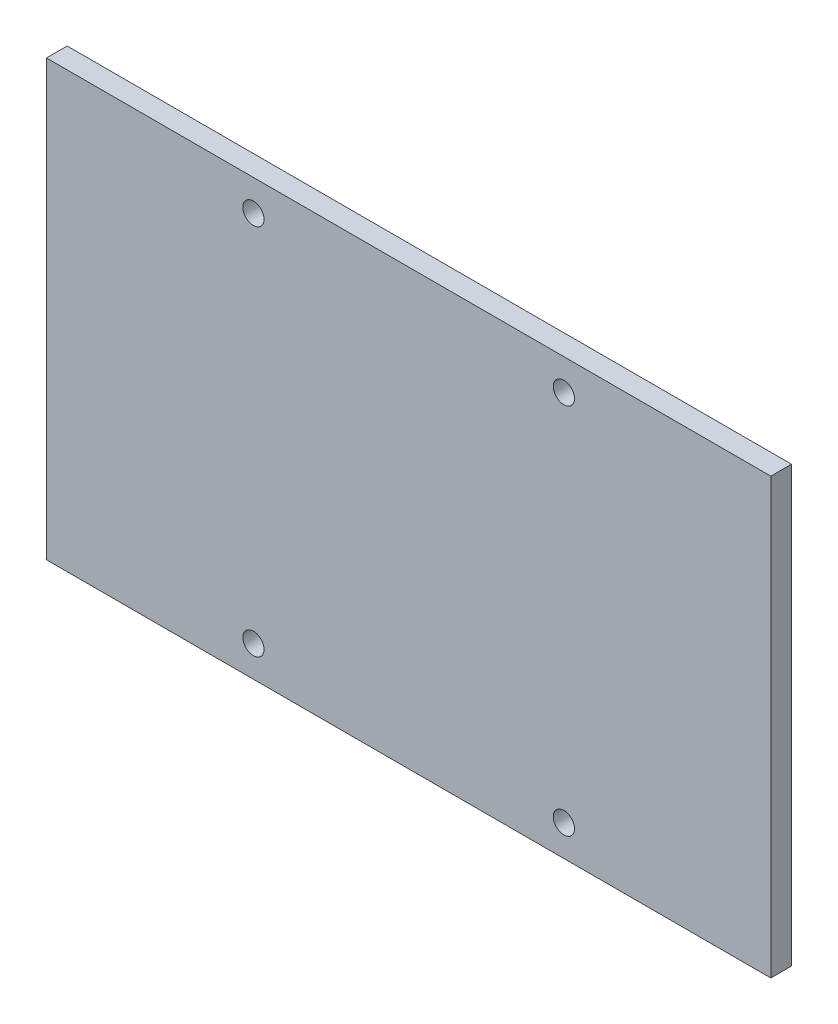
from build123d import *

# Parameters (mm, degrees)
SKETCH_1_W      = 70
SKETCH_1_H      = 42
SKETCH_1_R      = 1.025
EXTRUDE_1_DEPTH = 2


with BuildPart() as part:
    # 草图1 → 凸台-拉伸1 (new body)
    with BuildSketch(Plane.XY):
        Rectangle(SKETCH_1_W, SKETCH_1_H)
        with Locations((-15, 18)):
            Circle(SKETCH_1_R, mode=Mode.SUBTRACT)
        with Locations((15, 18)):
            Circle(SKETCH_1_R, mode=Mode.SUBTRACT)
        with Locations((15, -18)):
            Circle(SKETCH_1_R, mode=Mode.SUBTRACT)
        with Locations((-15, -18)):
            Circle(SKETCH_1_R, mode=Mode.SUBTRACT)
    extrude(amount=EXTRUDE_1_DEPTH)


solid = part.part
